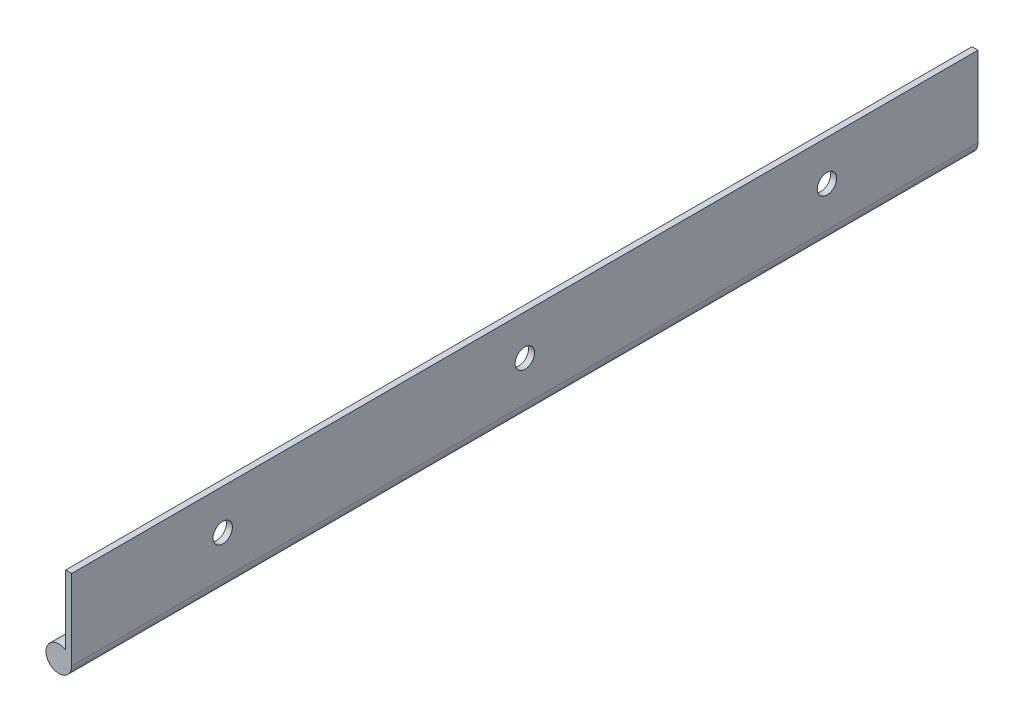
from build123d import *

# Parameters (mm, degrees)
BOSS_EXTRUDE2_DEPTH       = 152.4
F_4_CLEARANCE_HOLE1_D     = 3.2639
F_4_CLEARANCE_HOLE1_DEPTH = 1.524
F_4_CLEARANCE_HOLE1_TIP   = 0.980574487


with BuildPart() as part:
    # Sketch2 → Boss-Extrude2 (new body)
    with BuildSketch(Plane.XY):
        with BuildLine():
            Line((-0.508, -4.915254952), (-0.508, 6.746875))
            Line((-0.508, 6.746875), (0.508, 6.746875))
            Line((0.508, 6.746875), (0.508, -6.746875))
            ThreePointArc((0.508, -6.746875), (-3.538990731, -7.794143829), (-0.508, -4.915254952))
        make_face()
    extrude(amount=BOSS_EXTRUDE2_DEPTH)

    # #4 Clearance Hole1
    with Locations(Plane.ZY.offset(0.508)):
        with Locations((25.4, 0), (76.2, 0), (127, 0)):
            Hole(F_4_CLEARANCE_HOLE1_D / 2, depth=F_4_CLEARANCE_HOLE1_DEPTH)
            with Locations((0, 0, -(F_4_CLEARANCE_HOLE1_DEPTH + F_4_CLEARANCE_HOLE1_TIP / 2))):  # 118° drill point
                Cone(0, F_4_CLEARANCE_HOLE1_D / 2, F_4_CLEARANCE_HOLE1_TIP, mode=Mode.SUBTRACT)


solid = part.part
